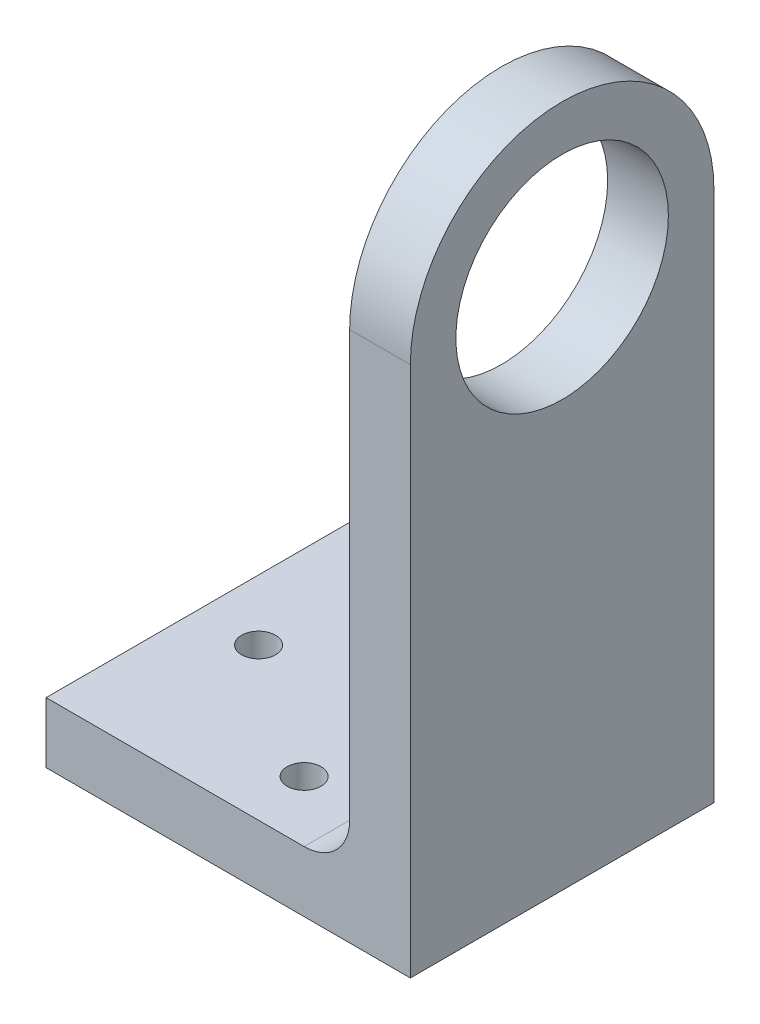
from build123d import *

# Parameters (mm, degrees)
SKETCH3_R           = 11.1125
BOSS_EXTRUDE1_DEPTH = 6.35
SKETCH5_W           = 31.75
SKETCH5_H           = 6.35
BOSS_EXTRUDE2_DEPTH = 38.1
FILLET1_R           = 4.7625
SKETCH6_R           = 1.777000002
CUT_EXTRUDE1_DEPTH  = 7.35


with BuildPart() as part:
    # Sketch3 → Boss-Extrude1 (new body)
    with BuildSketch(Plane(origin=(0, 0, 0), x_dir=(0, 0, -1), z_dir=(1, 0, 0))):
        with BuildLine():
            Line((0, 0), (31.75, 0))
            Line((31.75, 0), (31.75, 49.2125))
            ThreePointArc((31.75, 49.2125), (15.875, 65.0875), (0, 49.2125))
            Line((0, 49.2125), (0, 0))
        make_face()
        with Locations((15.875, 49.2125)):
            Circle(SKETCH3_R, mode=Mode.SUBTRACT)
    extrude(amount=BOSS_EXTRUDE1_DEPTH)

    # Sketch5 → Boss-Extrude2 (add)
    with BuildSketch(Plane(origin=(6.35, 0, 0), x_dir=(0, 0, -1), z_dir=(1, 0, 0))):
        with Locations((15.875, -3.175)):
            Rectangle(SKETCH5_W, SKETCH5_H)
    extrude(amount=-BOSS_EXTRUDE2_DEPTH)

    # Fillet1
    fillet1_edges = [part.edges().sort_by_distance(p)[0] for p in [
        (0, 0, -15.875),
    ]]
    fillet(fillet1_edges, radius=FILLET1_R)

    # Sketch6 → Cut-Extrude1 (cut, through all)
    with BuildSketch(Plane(origin=(0, 0, 0), x_dir=(1, 0, 0), z_dir=(0, 1, 0))):
        with Locations((-11.1125, 6.35)):
            Circle(SKETCH6_R)
        with Locations((-25.4, 15.875)):
            Circle(SKETCH6_R)
        with Locations((-11.1125, 25.4)):
            Circle(SKETCH6_R)
    extrude(amount=-CUT_EXTRUDE1_DEPTH, mode=Mode.SUBTRACT)


solid = part.part
